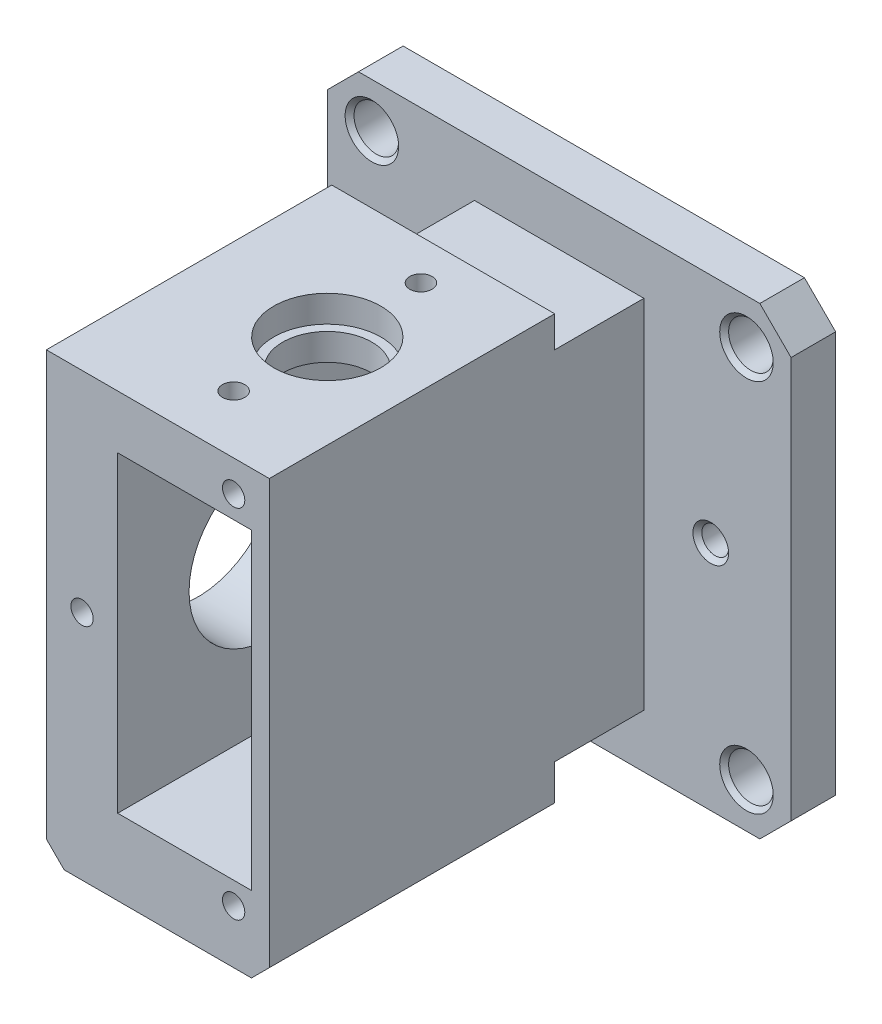
from build123d import *

# Parameters (mm, degrees)
SKETCH_1_W          = 52
SKETCH_1_H          = 52
EXTRUDE_1_DEPTH     = 5
CUT_EXTRUDE_1_DEPTH = 6
CHAMFER_1_SIZE      = 3.5
CHAMFER_2_SIZE      = 0.5
SKETCH_3_W          = 19
SKETCH_3_H          = 40
EXTRUDE_2_DEPTH     = 42
SKETCH_4_W          = 25
SKETCH_4_H          = 52
EXTRUDE_3_DEPTH     = 32
SKETCH_6_W          = 15
SKETCH_6_H          = 35
CUT_EXTRUDE_2_DEPTH = 48
CUT_EXTRUDE_3_REACH = 43.5
SKETCH_7_R          = 9
M3X0_51_D           = 2.5
M3X0_51_DEPTH       = 5.5
M3X0_51_TIP         = 0.751075774
CHAMFER_3_SIZE      = 2
M3X0_52_D           = 2.5
M3X0_52_DEPTH       = 5.5
M3X0_52_TIP         = 0.751075774
SKETCH_13_R         = 3.1
CUT_EXTRUDE_4_DEPTH = 7
CUT_EXTRUDE_5_REACH = 47
SKETCH_14_R         = 1.55
CHAMFER_4_SIZE      = 1
SKETCH_15_W         = 25
SKETCH_15_H         = 32
CUT_EXTRUDE_6_DEPTH = 2.5
SKETCH_16_R         = 6
CUT_EXTRUDE_7_DEPTH = 3
CUT_EXTRUDE_8_REACH = 48.5
SKETCH_17_R         = 5
M3X0_53_D           = 2.5
M3X0_53_DEPTH       = 4.5
M3X0_53_TIP         = 0.751075774
CUT_EXTRUDE_9_REACH = 49
SKETCH_20_R         = 1.5
CHAMFER_5_SIZE      = 0.5


with BuildPart() as part:
    # Эскиз1 → Бобышка-Вытянуть1 (new body)
    with BuildSketch(Plane.XY):
        Rectangle(SKETCH_1_W, SKETCH_1_H)
    extrude(amount=EXTRUDE_1_DEPTH)

    # Эскиз2 → Вырез-Вытянуть1 (cut, through all)
    with BuildSketch(Plane.XY.offset(5)):
        with BuildLine():
            ThreePointArc((-18.5, 21), (-22.767766953, 22.767766953), (-21, 18.5))
            Line((-21, 18.5), (-21, 21))
            Line((-21, 21), (-18.5, 21))
        make_face()
        with BuildLine():
            Line((-21, 21), (-21, 18.5))
            ThreePointArc((-21, 18.5), (-19.232233047, 19.232233047), (-18.5, 21))
            Line((-18.5, 21), (-21, 21))
        make_face()
        with BuildLine():
            ThreePointArc((18.5, 21), (19.232233047, 19.232233047), (21, 18.5))
            Line((21, 18.5), (21, 21))
            Line((21, 21), (18.5, 21))
        make_face()
        with BuildLine():
            Line((21, 21), (21, 18.5))
            ThreePointArc((21, 18.5), (22.767766953, 19.232233047), (23.5, 21))
            ThreePointArc((23.5, 21), (21, 23.5), (18.5, 21))
            Line((18.5, 21), (21, 21))
        make_face()
        with BuildLine():
            Line((-21, -18.5), (-21, -21))
            Line((-21, -21), (-18.5, -21))
            ThreePointArc((-18.5, -21), (-19.232233047, -19.232233047), (-21, -18.5))
        make_face()
        with BuildLine():
            Line((-18.5, -21), (-21, -21))
            Line((-21, -21), (-21, -18.5))
            ThreePointArc((-21, -18.5), (-22.767766953, -22.767766953), (-18.5, -21))
        make_face()
        with BuildLine():
            ThreePointArc((21, -18.5), (19.232233047, -19.232233047), (18.5, -21))
            Line((18.5, -21), (21, -21))
            Line((21, -21), (21, -18.5))
        make_face()
        with BuildLine():
            Line((21, -21), (18.5, -21))
            ThreePointArc((18.5, -21), (21, -23.5), (23.5, -21))
            ThreePointArc((23.5, -21), (22.767766953, -19.232233047), (21, -18.5))
            Line((21, -18.5), (21, -21))
        make_face()
    extrude(amount=-CUT_EXTRUDE_1_DEPTH, mode=Mode.SUBTRACT)

    # Фаска1
    chamfer_1_edges = [part.edges().sort_by_distance(p)[0] for p in [
        (26, -26, 2.5),
        (-26, -26, 2.5),
        (-26, 26, 2.5),
        (26, 26, 2.5),
    ]]
    chamfer(chamfer_1_edges, length=CHAMFER_1_SIZE)

    # Фаска2
    chamfer_2_edges = [part.edges().sort_by_distance(p)[0] for p in [
        (23.5, 21, 5),
        (-21, 23.5, 5),
        (-23.5, -21, 5),
        (18.5, -21, 5),
    ]]
    chamfer(chamfer_2_edges, length=CHAMFER_2_SIZE)

    # Эскиз3 → Бобышка-Вытянуть2 (add)
    with BuildSketch(Plane.XY.offset(5)):
        Rectangle(SKETCH_3_W, SKETCH_3_H)
    extrude(amount=EXTRUDE_2_DEPTH)

    # Эскиз4 → Бобышка-Вытянуть3 (add)
    with BuildSketch(Plane.XY.offset(47)):
        with Locations((-3, 0)):
            Rectangle(SKETCH_4_W, SKETCH_4_H)
    extrude(amount=-EXTRUDE_3_DEPTH)

    # Эскиз6 → Вырез-Вытянуть2 (cut, through all)
    with BuildSketch(Plane.XY.offset(47)):
        Rectangle(SKETCH_6_W, SKETCH_6_H)
    extrude(amount=-CUT_EXTRUDE_2_DEPTH, mode=Mode.SUBTRACT)

    # Эскиз7 → Вырез-Вытянуть3 (cut, up to next)
    with BuildSketch(Plane.ZY.offset(15.5), mode=Mode.PRIVATE) as cut_extrude_3_sk1:
        with Locations((30, 0)):
            Circle(SKETCH_7_R)
    cut_extrude_3_tool1 = extrude(cut_extrude_3_sk1.sketch, amount=-CUT_EXTRUDE_3_REACH, mode=Mode.PRIVATE) & part.part
    add(cut_extrude_3_tool1.solids().sort_by_distance((-15.5, 0, 30))[0], mode=Mode.SUBTRACT)

    # Отверстие обработанное метчиком M3x0.51
    with Locations(Plane(origin=(-15.5, 11, 39), x_dir=(0, 0, -1), z_dir=(-1, 0, 0))):
        with Locations((0, 0), (0, 22), (18, 22), (18, 0)):
            Hole(M3X0_51_D / 2, depth=M3X0_51_DEPTH)
            with Locations((0, 0, -(M3X0_51_DEPTH + M3X0_51_TIP / 2))):  # 118° drill point
                Cone(0, M3X0_51_D / 2, M3X0_51_TIP, mode=Mode.SUBTRACT)

    # Фаска3
    chamfer_3_edges = [part.edges().sort_by_distance(p)[0] for p in [
        (9.5, 26, 31),
        (9.5, -26, 31),
        (-15.5, -26, 31),
        (-15.5, 26, 31),
    ]]
    chamfer(chamfer_3_edges, length=CHAMFER_3_SIZE)

    # Отверстие обработанное метчиком M3x0.52
    with Locations(Plane(origin=(5.5, 20, 47), x_dir=(1, 0, 0), z_dir=(0, 0, 1))):
        with Locations((0, 0), (-17, -20), (0, -40)):
            Hole(M3X0_52_D / 2, depth=M3X0_52_DEPTH)
            with Locations((0, 0, -(M3X0_52_DEPTH + M3X0_52_TIP / 2))):  # 118° drill point
                Cone(0, M3X0_52_D / 2, M3X0_52_TIP, mode=Mode.SUBTRACT)

    # Эскиз13 → Вырез-Вытянуть4 (cut)
    with BuildSketch(Plane(origin=(0, -26, 0), x_dir=(-1, 0, 0), z_dir=(0, -1, 0))):
        with Locations((1, -30)):
            Circle(SKETCH_13_R)
    extrude(amount=-CUT_EXTRUDE_4_DEPTH, mode=Mode.SUBTRACT)

    # Эскиз14 → Вырез-Вытянуть5 (cut, up to next)
    with BuildSketch(Plane.XZ.offset(19), mode=Mode.PRIVATE) as cut_extrude_5_sk1:
        with Locations((-1, 30)):
            Circle(SKETCH_14_R)
    cut_extrude_5_tool1 = extrude(cut_extrude_5_sk1.sketch, amount=-CUT_EXTRUDE_5_REACH, mode=Mode.PRIVATE) & part.part
    add(cut_extrude_5_tool1.solids().sort_by_distance((-1, -19, 30))[0], mode=Mode.SUBTRACT)

    # Фаска4
    chamfer_4_edges = [part.edges().sort_by_distance(p)[0] for p in [
        (2.1, -26, 30),
    ]]
    chamfer(chamfer_4_edges, length=CHAMFER_4_SIZE)

    # Эскиз15 → Вырез-Вытянуть6 (cut)
    with BuildSketch(Plane(origin=(0, 26, 0), x_dir=(1, 0, 0), z_dir=(0, 1, 0))):
        with Locations((-3, -31)):
            Rectangle(SKETCH_15_W, SKETCH_15_H)
    extrude(amount=-CUT_EXTRUDE_6_DEPTH, mode=Mode.SUBTRACT)

    # Эскиз16 → Вырез-Вытянуть7 (cut)
    with BuildSketch(Plane(origin=(0, 23.5, 0), x_dir=(1, 0, 0), z_dir=(0, 1, 0))):
        with Locations((-1, -30)):
            Circle(SKETCH_16_R)
    extrude(amount=-CUT_EXTRUDE_7_DEPTH, mode=Mode.SUBTRACT)

    # Эскиз17 → Вырез-Вытянуть8 (cut, up to next)
    with BuildSketch(Plane(origin=(0, 20.5, 0), x_dir=(1, 0, 0), z_dir=(0, 1, 0)), mode=Mode.PRIVATE) as cut_extrude_8_sk1:
        with Locations((-1, -30)):
            Circle(SKETCH_17_R)
    cut_extrude_8_tool1 = extrude(cut_extrude_8_sk1.sketch, amount=-CUT_EXTRUDE_8_REACH, mode=Mode.PRIVATE) & part.part
    add(cut_extrude_8_tool1.solids().sort_by_distance((-1, 20.5, 30))[0], mode=Mode.SUBTRACT)

    # Отверстие обработанное метчиком M3x0.53
    with Locations(Plane(origin=(-1, 23.5, 40.5), x_dir=(0, 0, 1), z_dir=(0, 1, 0))):
        with Locations((0, 0), (-21, 0)):
            Hole(M3X0_53_D / 2, depth=M3X0_53_DEPTH)
            with Locations((0, 0, -(M3X0_53_DEPTH + M3X0_53_TIP / 2))):  # 118° drill point
                Cone(0, M3X0_53_D / 2, M3X0_53_TIP, mode=Mode.SUBTRACT)

    # Эскиз20 → Вырез-Вытянуть9 (cut, up to next)
    with BuildSketch(Plane(origin=(0, 0, 0), x_dir=(-1, 0, 0), z_dir=(0, 0, -1)), mode=Mode.PRIVATE) as cut_extrude_9_sk1:
        with Locations((-17, 0)):
            Circle(SKETCH_20_R)
    cut_extrude_9_tool1 = extrude(cut_extrude_9_sk1.sketch, amount=-CUT_EXTRUDE_9_REACH, mode=Mode.PRIVATE) & part.part
    add(cut_extrude_9_tool1.solids().sort_by_distance((17, 0, 0))[0], mode=Mode.SUBTRACT)
    # Эскиз20 → Вырез-Вытянуть9 (cut, up to next)
    with BuildSketch(Plane(origin=(0, 0, 0), x_dir=(-1, 0, 0), z_dir=(0, 0, -1)), mode=Mode.PRIVATE) as cut_extrude_9_sk2:
        with Locations((17, 0)):
            Circle(SKETCH_20_R)
    cut_extrude_9_tool2 = extrude(cut_extrude_9_sk2.sketch, amount=-CUT_EXTRUDE_9_REACH, mode=Mode.PRIVATE) & part.part
    add(cut_extrude_9_tool2.solids().sort_by_distance((-17, 0, 0))[0], mode=Mode.SUBTRACT)

    # Фаска5
    chamfer_5_edges = [part.edges().sort_by_distance(p)[0] for p in [
        (18.5, 0, 5),
        (-15.5, 0, 5),
    ]]
    chamfer(chamfer_5_edges, length=CHAMFER_5_SIZE)


solid = part.part
